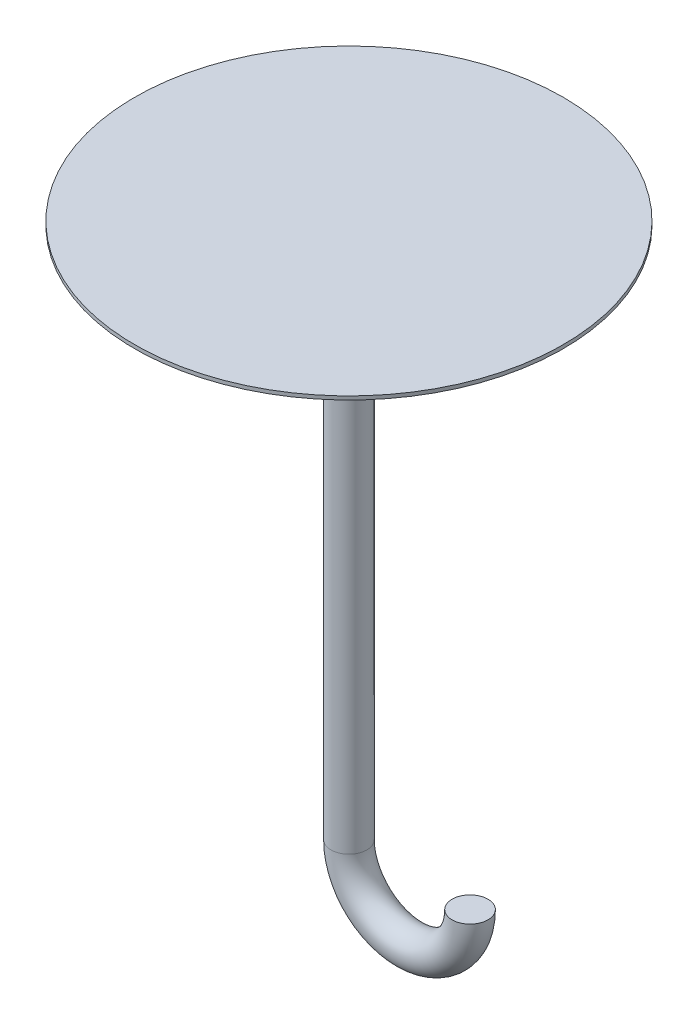
from build123d import *

# Parameters (mm, degrees)
SKETCH5_R           = 5.017644021
SKETCH8_R           = 60
BOSS_EXTRUDE3_DEPTH = 1


with BuildPart() as part:
    # Sweep2: sweep along a path in Sketch1
    with BuildLine(Plane.XY) as sweep2_path:
        Line((0, 68.373689823), (0, -81.626310177))
        ThreePointArc((0, -81.626310177), (11.935275606, -93.561585783), (23.870551211, -81.626310177))
    # Sketch5 → Sweep2 (sweep)
    with BuildSketch(Plane(origin=(0, 68.373689823, 0), x_dir=(-1, 0, 0), z_dir=(0, -1, 0))):
        with Locations((5.017641314, -0.00521205)):
            Circle(SKETCH5_R)
    sweep(path=sweep2_path.line)

    # Sketch8 → Boss-Extrude3 (add)
    with BuildSketch(Plane(origin=(0, 68.373689823, 0), x_dir=(-1, 0, 0), z_dir=(0, -1, 0))):
        with Locations((5.017641314, -0.00521205)):
            Circle(SKETCH8_R)
    extrude(amount=BOSS_EXTRUDE3_DEPTH)


solid = part.part
